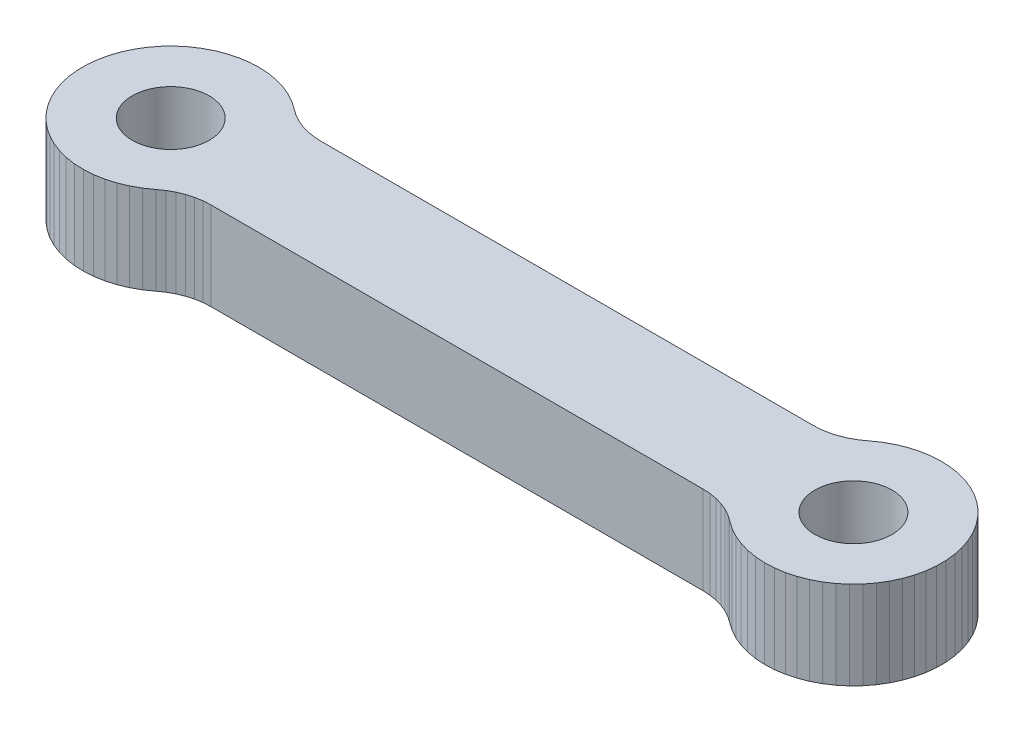
from build123d import *

# Parameters (mm, degrees)
SKETCH1_R           = 1.750000093
SKETCH1_R_2         = 1.749998765
BOSS_EXTRUDE1_DEPTH = 4.00000019


with BuildPart() as part:
    # Sketch1 → Boss-Extrude1 (new body)
    with BuildSketch(Plane(origin=(0, 4.00000019, 0), x_dir=(1, 0, 0), z_dir=(0, 1, 0))):
        Polygon((32.525639981, -7.142858114), (32.88276121, -7.393712178), (33.265069127, -7.604169194), (33.66804868, -7.771722972), (34.086868167, -7.894380018), (34.516561776, -7.97067862), (34.952010959, -7.99971167), (35.388030112, -7.981133647), (35.81944108, -7.915167138), (36.241080612, -7.802593987), (36.647960544, -7.644756231), (37.035208195, -7.443531882), (37.39824146, -7.201318163), (37.732720375, -6.920996122), (38.034681231, -6.605904084), (38.300510496, -6.259791087), (38.527049124, -5.886779167), (38.711611181, -5.491307005), (38.85198012, -5.078083836), (38.946498185, -4.652027041), (38.994051516, -4.218208138), (38.994051516, -3.781792009), (38.946498185, -3.347974038), (38.85198012, -2.92191701), (38.711611181, -2.508692909), (38.527049124, -2.11322098), (38.300510496, -1.740208943), (38.034681231, -1.394096995), (37.732720375, -1.079004025), (37.39824146, -0.798682508), (37.035208195, -0.556467974), (36.647960544, -0.355244207), (36.241080612, -0.197406596), (35.81944108, -0.084833708), (35.388030112, -0.0188658), (34.952010959, -0.000288244), (34.516561776, -0.02932176), (34.086868167, -0.105620798), (33.66804868, -0.228277393), (33.265069127, -0.39583139), (32.88276121, -0.606288377), (32.525639981, -0.857143023), (32.252710313, -1.048453967), (31.960248947, -1.208308968), (31.65185824, -1.334734028), (31.331341714, -1.42616895), (31.002659351, -1.481484971), (30.669869855, -1.500000013), (8.330127224, -1.500000013), (7.997341454, -1.481484971), (7.668660954, -1.42616895), (7.348147221, -1.334734028), (7.039752789, -1.208308968), (6.747287232, -1.048453967), (6.474358961, -0.857143023), (6.117243785, -0.606288377), (5.73492609, -0.39583139), (5.331956781, -0.228277393), (4.913132172, -0.105620798), (4.483437166, -0.02932176), (4.047987983, -0.000288244), (3.611967899, -0.0188658), (3.180566011, -0.084833708), (2.758919029, -0.197406596), (2.352046082, -0.355244207), (1.964788884, -0.556467974), (1.601757947, -0.798682508), (1.267276006, -1.079004025), (0.965322892, -1.394096995), (0.699493627, -1.740208943), (0.472952612, -2.11322098), (0.288396404, -2.508692909), (0.148022096, -2.92191701), (0.053500291, -3.347974038), (0.005956274, -3.781792009), (0.005956274, -4.218208138), (0.053500291, -4.652027041), (0.148022096, -5.078083836), (0.288396404, -5.491307005), (0.472952612, -5.886779167), (0.699493627, -6.259791087), (0.965322892, -6.605904084), (1.267276006, -6.920996122), (1.601757947, -7.201318163), (1.964788884, -7.443531882), (2.352046082, -7.644756231), (2.758919029, -7.802593987), (3.180566011, -7.915167138), (3.611967899, -7.981133647), (4.047987983, -7.99971167), (4.483437166, -7.97067862), (4.913132172, -7.894380018), (5.331956781, -7.771722972), (5.73492609, -7.604169194), (6.117243785, -7.393712178), (6.474358961, -7.142858114), (6.747287232, -6.951545831), (7.039752789, -6.791692227), (7.348147221, -6.66526705), (7.668660954, -6.573832128), (7.997341454, -6.518514827), (8.330127224, -6.500000134), (30.669869855, -6.500000134), (31.002659351, -6.518514827), (31.331341714, -6.573832128), (31.65185824, -6.66526705), (31.960248947, -6.791692227), (32.252710313, -6.951545831), align=None)
        with Locations((4.006235525, -3.998948436)):
            Circle(SKETCH1_R, mode=Mode.SUBTRACT)
        with Locations((35.000000078, -3.999998668)):
            Circle(SKETCH1_R_2, mode=Mode.SUBTRACT)
    extrude(amount=-BOSS_EXTRUDE1_DEPTH)


solid = part.part
